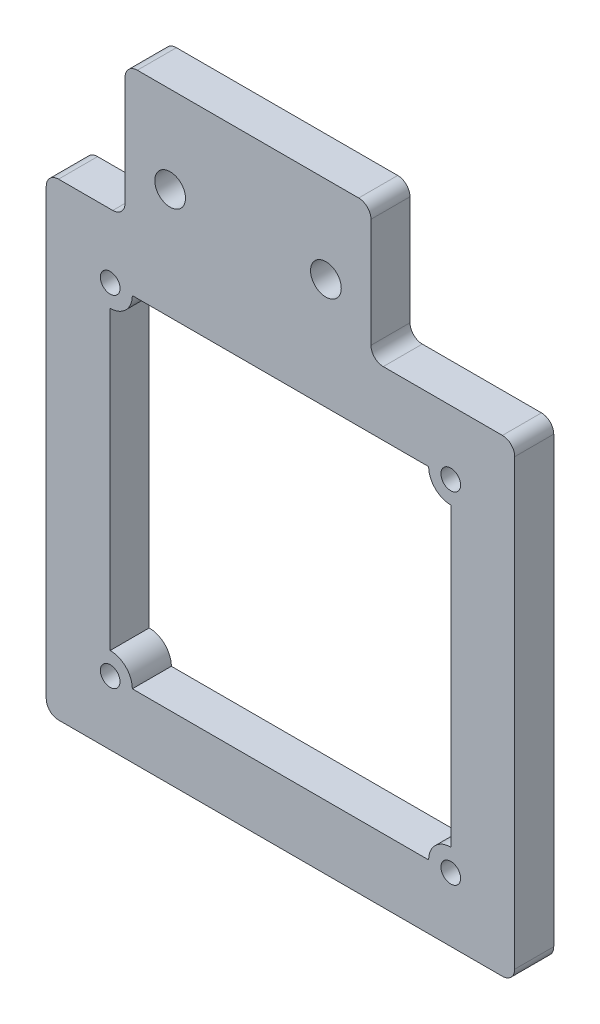
from build123d import *

# Parameters (mm, degrees)
SKETCH1_R           = 0.8
SKETCH1_R_2         = 1.25
BOSS_EXTRUDE1_DEPTH = 3.175
FILLET1_R           = 1


with BuildPart() as part:
    # Sketch1 → Boss-Extrude1 (new body)
    with BuildSketch(Plane.XY):
        Polygon((31.690894529, -38.1), (31.690894529, 0), (20, 0), (20, 10.87553853), (0, 10.87553853), (0, 0), (-6.409105471, 0), (-6.409105471, -38.1), align=None)
        with Locations((26.490894529, -32.9)):
            Circle(SKETCH1_R, mode=Mode.SUBTRACT)
        with Locations((-1.209105471, -32.9)):
            Circle(SKETCH1_R, mode=Mode.SUBTRACT)
        with Locations((-1.209105471, -5.2)):
            Circle(SKETCH1_R, mode=Mode.SUBTRACT)
        with Locations((26.490894529, -5.2)):
            Circle(SKETCH1_R, mode=Mode.SUBTRACT)
        with Locations((16.335044769, 3.811593223)):
            Circle(SKETCH1_R_2, mode=Mode.SUBTRACT)
        with Locations((3.664955231, 3.811593223)):
            Circle(SKETCH1_R_2, mode=Mode.SUBTRACT)
        with BuildLine():
            Line((26.490894529, -7), (26.490894529, -31.1))
            ThreePointArc((26.490894529, -31.1), (25.218102323, -31.627207794), (24.690894529, -32.9))
            Line((24.690894529, -32.9), (0.590894529, -32.9))
            ThreePointArc((0.590894529, -32.9), (0.063686735, -31.627207794), (-1.209105471, -31.1))
            Line((-1.209105471, -31.1), (-1.209105471, -7))
            ThreePointArc((-1.209105471, -7), (0.063686735, -6.472792206), (0.590894529, -5.2))
            Line((0.590894529, -5.2), (24.690894529, -5.2))
            ThreePointArc((24.690894529, -5.2), (25.218102323, -6.472792206), (26.490894529, -7))
        make_face(mode=Mode.SUBTRACT)
    extrude(amount=BOSS_EXTRUDE1_DEPTH)

    # Fillet1
    fillet1_edges = [part.edges().sort_by_distance(p)[0] for p in [
        (20, 10.87553853, 1.5875),
        (20, 0, 1.5875),
        (31.690894529, 0, 1.5875),
        (31.690894529, -38.1, 1.5875),
        (-6.409105471, -38.1, 1.5875),
        (-6.409105471, 0, 1.5875),
        (0, 0, 1.5875),
        (0, 10.87553853, 1.5875),
    ]]
    fillet(fillet1_edges, radius=FILLET1_R)


solid = part.part
